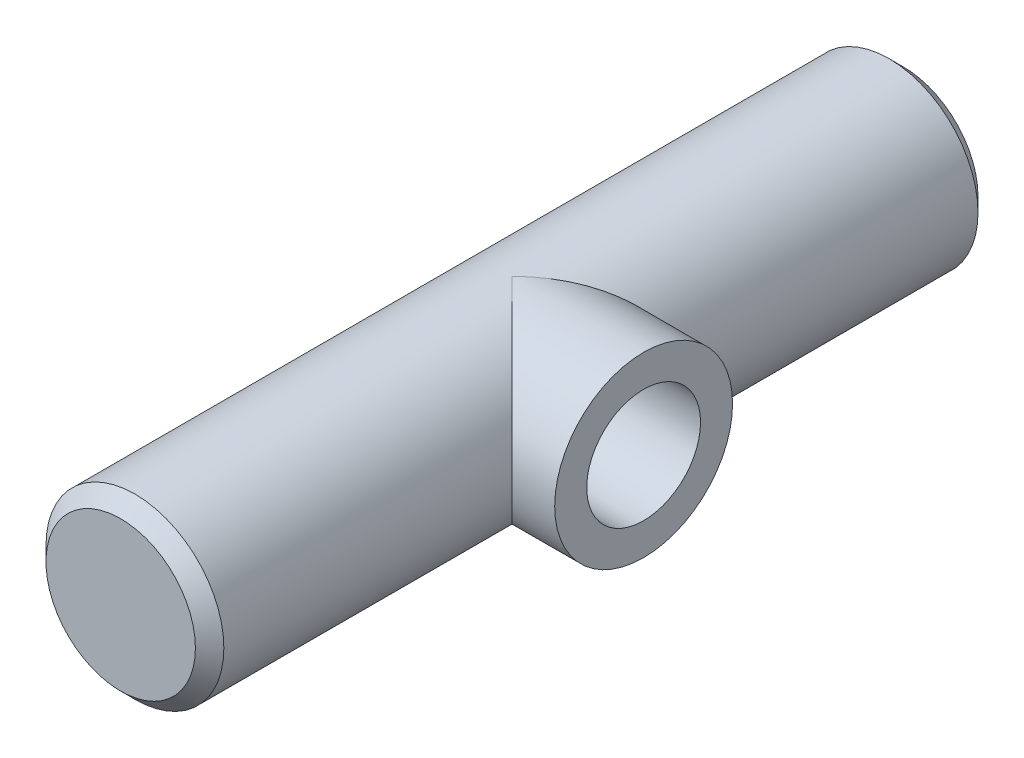
from build123d import *

# Parameters (mm, degrees)
SKETCH3_R           = 12.5
BOSS_EXTRUDE1_DEPTH = 110
SKETCH4_R           = 12.5
BOSS_EXTRUDE2_DEPTH = 18.5
CHAMFER1_SIZE       = 2
SKETCH5_R           = 8
CUT_EXTRUDE1_DEPTH  = 18.5


with BuildPart() as part:
    # Sketch3 → Boss-Extrude1 (new body)
    with BuildSketch(Plane.XY):
        Circle(SKETCH3_R)
    extrude(amount=BOSS_EXTRUDE1_DEPTH)

    # Sketch4 → Boss-Extrude2 (add)
    with BuildSketch(Plane(origin=(0, 0, 0), x_dir=(0, 0, -1), z_dir=(1, 0, 0))):
        with Locations((-55, 0)):
            Circle(SKETCH4_R)
    extrude(amount=BOSS_EXTRUDE2_DEPTH)

    # Chamfer1
    chamfer1_edges = [part.edges().sort_by_distance(p)[0] for p in [
        (-12.5, 0, 0),
        (-12.5, 0, 110),
    ]]
    chamfer(chamfer1_edges, length=CHAMFER1_SIZE)

    # Sketch5 → Cut-Extrude1 (cut)
    with BuildSketch(Plane(origin=(18.5, 0, 0), x_dir=(0, 0, -1), z_dir=(1, 0, 0))):
        with Locations((-55, 0)):
            Circle(SKETCH5_R)
    extrude(amount=-CUT_EXTRUDE1_DEPTH, mode=Mode.SUBTRACT)


solid = part.part
